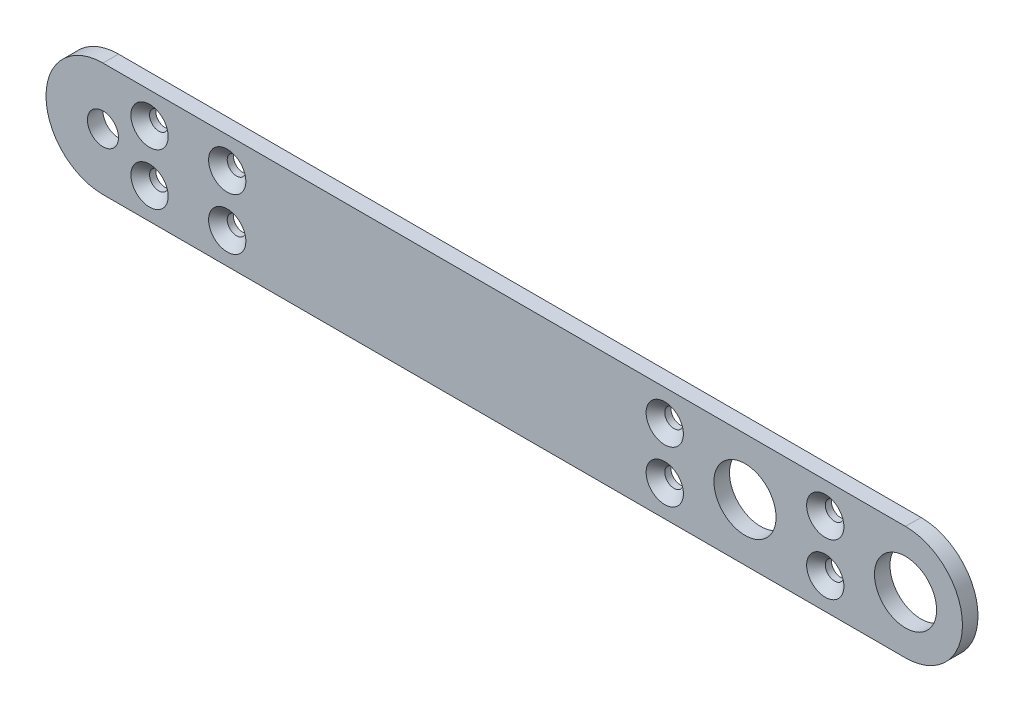
from build123d import *

# Parameters (mm, degrees)
SKETCH1_R                                    = 1.5
SKETCH1_R_2                                  = 3
BOSS_EXTRUDE1_DEPTH                          = 1.5
CSK_FOR_M1_6_COUNTERSUNK_FLAT_HEAD_S_2_COUNT = 2
CSK_FOR_M1_6_COUNTERSUNK_FLAT_HEAD_S_2_PITCH = 15.5
CSK_FOR_M1_6_COUNTERSUNK_FLAT_HEAD_S_3_COUNT = 2
CSK_FOR_M1_6_COUNTERSUNK_FLAT_HEAD_S_3_PITCH = 65.25
CSK_FOR_M1_6_COUNTERSUNK_FLAT_HEAD_S_4_COUNT = 2
CSK_FOR_M1_6_COUNTERSUNK_FLAT_HEAD_S_4_PITCH = 57.75


with BuildPart() as part:
    # Sketch1 → Boss-Extrude1 (new body)
    with BuildSketch(Plane.XY):
        with BuildLine():
            Line((15.5, 5.5), (-62, 5.5))
            ThreePointArc((-62, 5.5), (-67.5, 0), (-62, -5.5))
            Line((-62, -5.5), (15.5, -5.5))
            ThreePointArc((15.5, -5.5), (21, 0), (15.5, 5.5))
        make_face()
        with Locations((-62, 0)):
            Circle(SKETCH1_R, mode=Mode.SUBTRACT)
        Circle(SKETCH1_R_2, mode=Mode.SUBTRACT)
        with Locations((15.5, 0)):
            Circle(SKETCH1_R_2, mode=Mode.SUBTRACT)
    extrude(amount=BOSS_EXTRUDE1_DEPTH)

    # Sketch2 → CSK for M1.6 Countersunk Flat Head Screw1 (revolve, cut)
    with BuildSketch(Plane(origin=(7.75, 2.5, 1.5), x_dir=(0, -1, 0), z_dir=(1, 0, 0))):
        Polygon((0, 0), (0, 1.5), (0.9, 1.5), (0.9, 0.9), (1.8, 0), align=None)
    csk_for_m1_6_countersunk_flat_head_screw = revolve(axis=Axis((7.75, 2.5, 7.85), (0, 0, -1)), mode=Mode.SUBTRACT)

    # CSK for M1.6 Countersunk Flat Head S 2: CSK for M1.6 Countersunk Flat Head Screw1 ×2
    with Locations(*[(-i * CSK_FOR_M1_6_COUNTERSUNK_FLAT_HEAD_S_2_PITCH, 0, 0) for i in range(1, CSK_FOR_M1_6_COUNTERSUNK_FLAT_HEAD_S_2_COUNT)]):
        add(csk_for_m1_6_countersunk_flat_head_screw, mode=Mode.SUBTRACT)

    # CSK for M1.6 Countersunk Flat Head S 3: CSK for M1.6 Countersunk Flat Head Screw1 ×2
    with Locations(*[(-i * CSK_FOR_M1_6_COUNTERSUNK_FLAT_HEAD_S_3_PITCH, 0, 0) for i in range(1, CSK_FOR_M1_6_COUNTERSUNK_FLAT_HEAD_S_3_COUNT)]):
        add(csk_for_m1_6_countersunk_flat_head_screw, mode=Mode.SUBTRACT)

    # CSK for M1.6 Countersunk Flat Head S 4: CSK for M1.6 Countersunk Flat Head Screw1 ×2
    with Locations(*[(-i * CSK_FOR_M1_6_COUNTERSUNK_FLAT_HEAD_S_4_PITCH, 0, 0) for i in range(1, CSK_FOR_M1_6_COUNTERSUNK_FLAT_HEAD_S_4_COUNT)]):
        add(csk_for_m1_6_countersunk_flat_head_screw, mode=Mode.SUBTRACT)

    # Mirror1: CSK for M1.6 Countersunk Flat Head Screw1 across plane
    add(csk_for_m1_6_countersunk_flat_head_screw.mirror(Plane.ZX), mode=Mode.SUBTRACT)

    # Mirror1 copy 1 sketch → Mirror1 copy 1 (revolve, cut)
    with BuildSketch(Plane(origin=(-7.75, -2.5, 1.5), x_dir=(0, 1, 0), z_dir=(1, 0, 0))):
        Polygon((0, 0), (0, -1.5), (0.9, -1.5), (0.9, -0.9), (1.8, 0), align=None)
    revolve(axis=Axis((-7.75, -2.5, 7.85), (0, 0, 1)), mode=Mode.SUBTRACT)

    # Mirror1 copy 2 sketch → Mirror1 copy 2 (revolve, cut)
    with BuildSketch(Plane(origin=(-57.5, -2.5, 1.5), x_dir=(0, 1, 0), z_dir=(1, 0, 0))):
        Polygon((0, 0), (0, -1.5), (0.9, -1.5), (0.9, -0.9), (1.8, 0), align=None)
    revolve(axis=Axis((-57.5, -2.5, 7.85), (0, 0, 1)), mode=Mode.SUBTRACT)

    # Mirror1 copy 3 sketch → Mirror1 copy 3 (revolve, cut)
    with BuildSketch(Plane(origin=(-50, -2.5, 1.5), x_dir=(0, 1, 0), z_dir=(1, 0, 0))):
        Polygon((0, 0), (0, -1.5), (0.9, -1.5), (0.9, -0.9), (1.8, 0), align=None)
    revolve(axis=Axis((-50, -2.5, 7.85), (0, 0, 1)), mode=Mode.SUBTRACT)


solid = part.part
